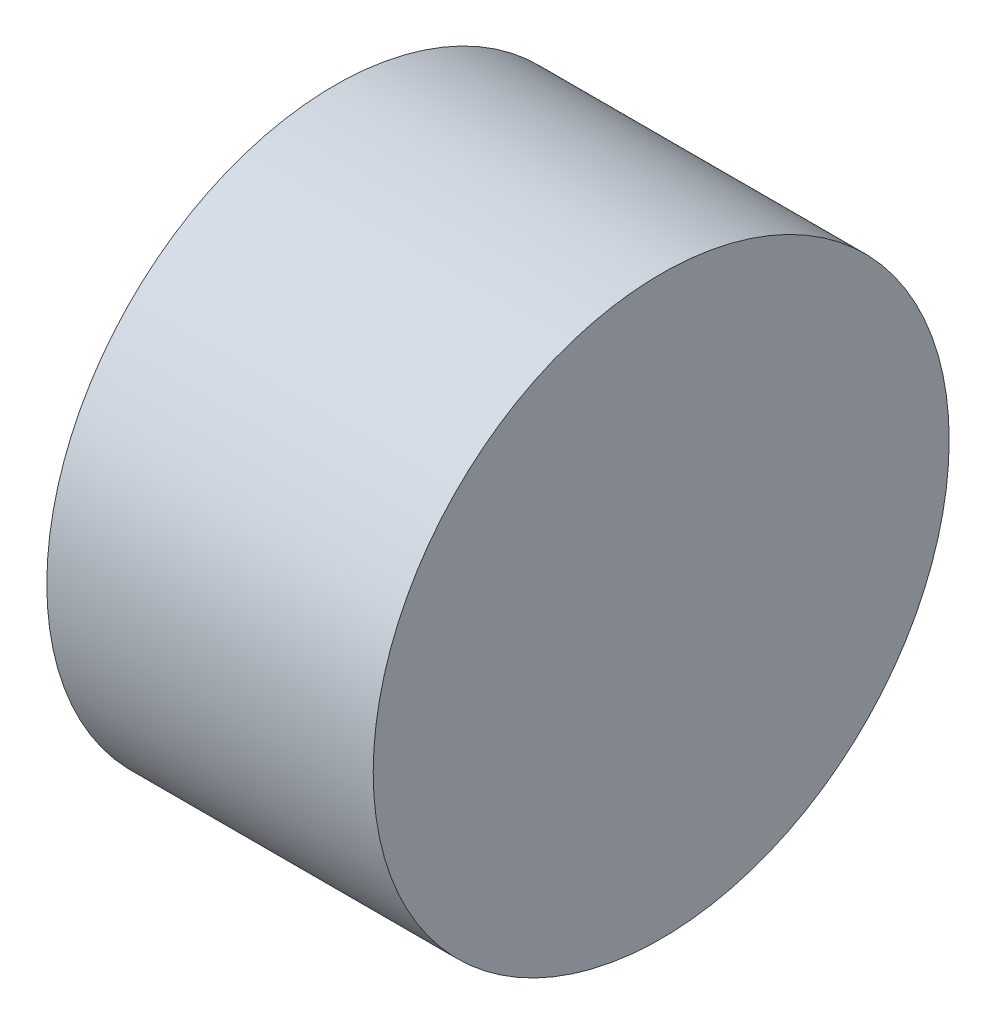
from build123d import *


with BuildPart() as part:
    # Sketch1 → Revolve7 (revolve)
    with BuildSketch(Plane(origin=(0, 0, 0), x_dir=(1, 0, 0), z_dir=(0, 1, 0))):
        with BuildLine():
            Line((65, 0), (65, 75))
            Line((65, 75), (-20, 75))
            Line((-20, 75), (-20, 34.641016151))
            ThreePointArc((-20, 34.641016151), (20, 34.641016151), (40, 0))
            Line((40, 0), (65, 0))
        make_face()
    revolve(axis=Axis((-21.462032589, 0, 0), (1, 0, 0)))


solid = part.part
